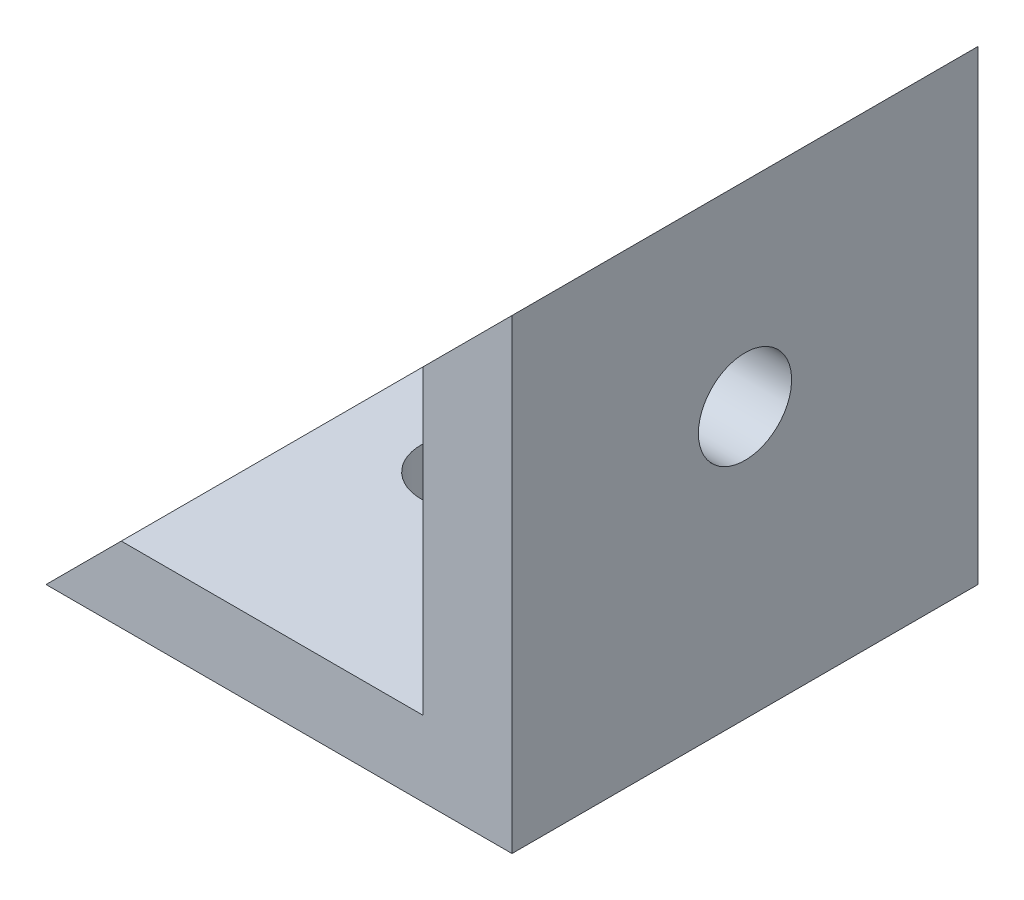
from build123d import *

# Parameters (mm, degrees)
IZIM1_W                     = 20
IZIM1_H                     = 20
Y_KSEKLIK_EKSTR_ZYON1_DEPTH = 20
KES_EKSTR_ZYON1_DEPTH       = 20
IZIM3_W                     = 17.224679165
IZIM3_H                     = 17.248412117
KES_EKSTR_ZYON2_DEPTH       = 20
IZIM4_R                     = 2
KES_EKSTR_ZYON3_DEPTH       = 20
IZIM10_R                    = 2
KES_EKSTR_ZYON10_DEPTH      = 10


with BuildPart() as part:
    # Çizim1 → Yükseklik-Ekstrüzyon1 (new body)
    with BuildSketch(Plane.XY):
        with Locations((-13.172756411, -5.622082974)):
            Rectangle(IZIM1_W, IZIM1_H)
    extrude(amount=Y_KSEKLIK_EKSTR_ZYON1_DEPTH)

    # Çizim2 → Kes-Ekstrüzyon1 (cut)
    with BuildSketch(Plane.XY.offset(20)):
        Polygon((-3.172756411, 4.377917026), (-23.172756411, -15.622082974), (-23.172756411, 4.377917026), align=None)
    extrude(amount=-KES_EKSTR_ZYON1_DEPTH, mode=Mode.SUBTRACT)

    # Çizim3 → Kes-Ekstrüzyon2 (cut)
    with BuildSketch(Plane.XY.offset(20)):
        with Locations((-15.601705124, -3.767784851)):
            Rectangle(IZIM3_W, IZIM3_H)
    extrude(amount=-KES_EKSTR_ZYON2_DEPTH, mode=Mode.SUBTRACT)

    # Çizim4 → Kes-Ekstrüzyon3 (cut)
    with BuildSketch(Plane.ZY.offset(6.989365541)):
        with Locations((10, -4.007036941)):
            Circle(IZIM4_R)
    extrude(amount=-KES_EKSTR_ZYON3_DEPTH, mode=Mode.SUBTRACT)

    # Çizim10 → Kes-Ekstrüzyon10 (cut)
    with BuildSketch(Plane(origin=(0, -12.391990909, 0), x_dir=(1, 0, 0), z_dir=(0, 1, 0))):
        with Locations((-15.081060976, -10)):
            Circle(IZIM10_R)
    extrude(amount=-KES_EKSTR_ZYON10_DEPTH, mode=Mode.SUBTRACT)


solid = part.part
